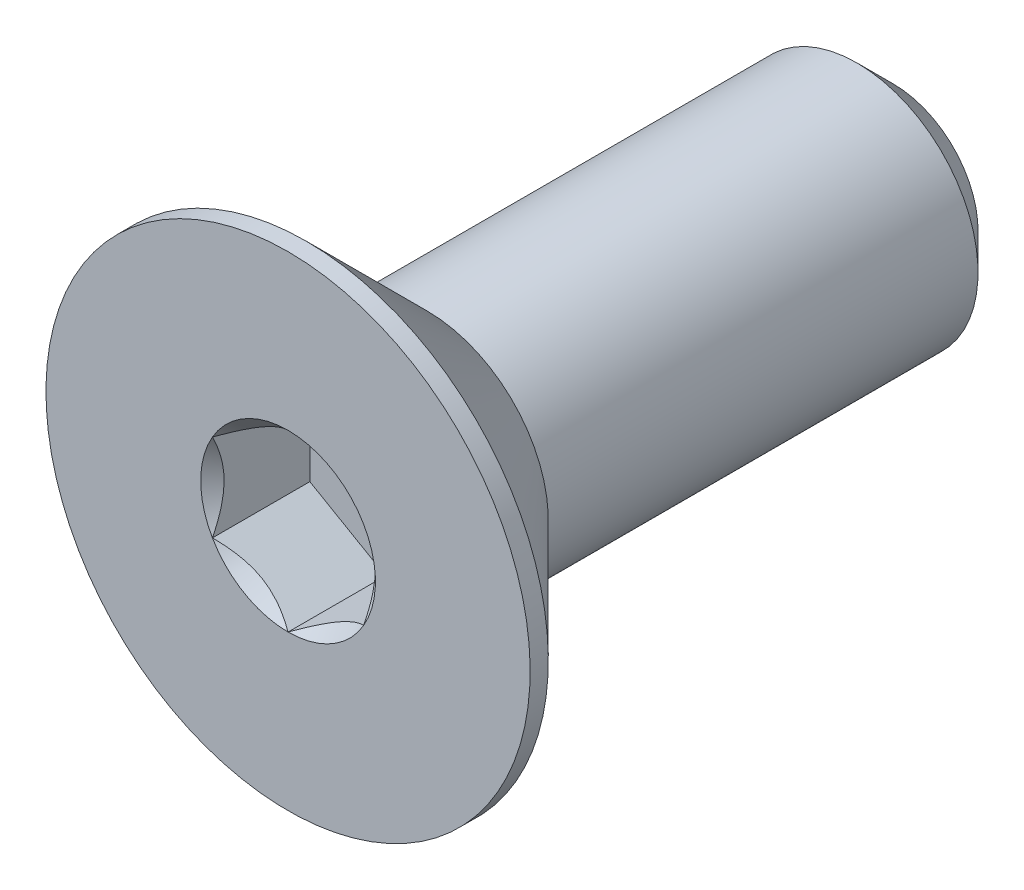
from build123d import *

# Parameters (mm, degrees)
SKETCH3_W          = 10
SKETCH3_H          = 2
CHAMFER1_SIZE      = 0.6
CUT_EXTRUDE1_DEPTH = 1.61
SKETCH9_R          = 1.443375673
CUT_EXTRUDE2_DEPTH = 1.61
CUT_EXTRUDE2_DRAFT = -45


with BuildPart() as part:
    # Sketch3 → Revolve1 (revolve)
    with BuildSketch(Plane(origin=(0, 0, 0), x_dir=(0, 0, -1), z_dir=(1, 0, 0))):
        with Locations((0, 1)):
            Rectangle(SKETCH3_W, SKETCH3_H)
    revolve(axis=Axis((0, 0, -5), (0, 0, 1)))

    # Chamfer1
    chamfer1_edges = [part.edges().sort_by_distance(p)[0] for p in [
        (0, -2, -5),
    ]]
    chamfer(chamfer1_edges, length=CHAMFER1_SIZE)

    # Sketch6 → Revolve2 (revolve)
    with BuildSketch(Plane(origin=(0, 0, 0), x_dir=(0, 0, -1), z_dir=(1, 0, 0))):
        Polygon((-5, 4), (-4.7, 4), (-2.7, 2), (-2.7, 0), (-5, 0), align=None)
    revolve(axis=Axis((0, 0, -5), (0, 0, 1)))

    # Sketch8 → Cut-Extrude1 (cut)
    with BuildSketch(Plane.XY.offset(5)):
        Polygon((0, 1.443375673), (-1.25, 0.721687836), (-1.25, -0.721687836), (0, -1.443375673), (1.25, -0.721687836), (1.25, 0.721687836), align=None)
    extrude(amount=-CUT_EXTRUDE1_DEPTH, mode=Mode.SUBTRACT)


with BuildPart() as cut_extrude2_tool:
    # Sketch9 → Cut-Extrude2 (with draft: the straight prism first)
    with BuildSketch(Plane.XY.offset(5)):
        Circle(SKETCH9_R)
    extrude(amount=-CUT_EXTRUDE2_DEPTH)
    # Cut-Extrude2: the draft: its side faces are tilted about the plane it starts from
    cut_extrude2_sides = [cut_extrude2_tool.faces().sort_by_distance(p)[0] for p in [
        (-1.443375673, 0, 4.195),
    ]]
    draft(cut_extrude2_sides, Plane.XY.offset(5), CUT_EXTRUDE2_DRAFT)


with BuildPart() as part_1:
    add(part.part)

    # Cut-Extrude2: cut by cut_extrude2_tool
    add(cut_extrude2_tool.part, mode=Mode.SUBTRACT)


solid = part_1.part
